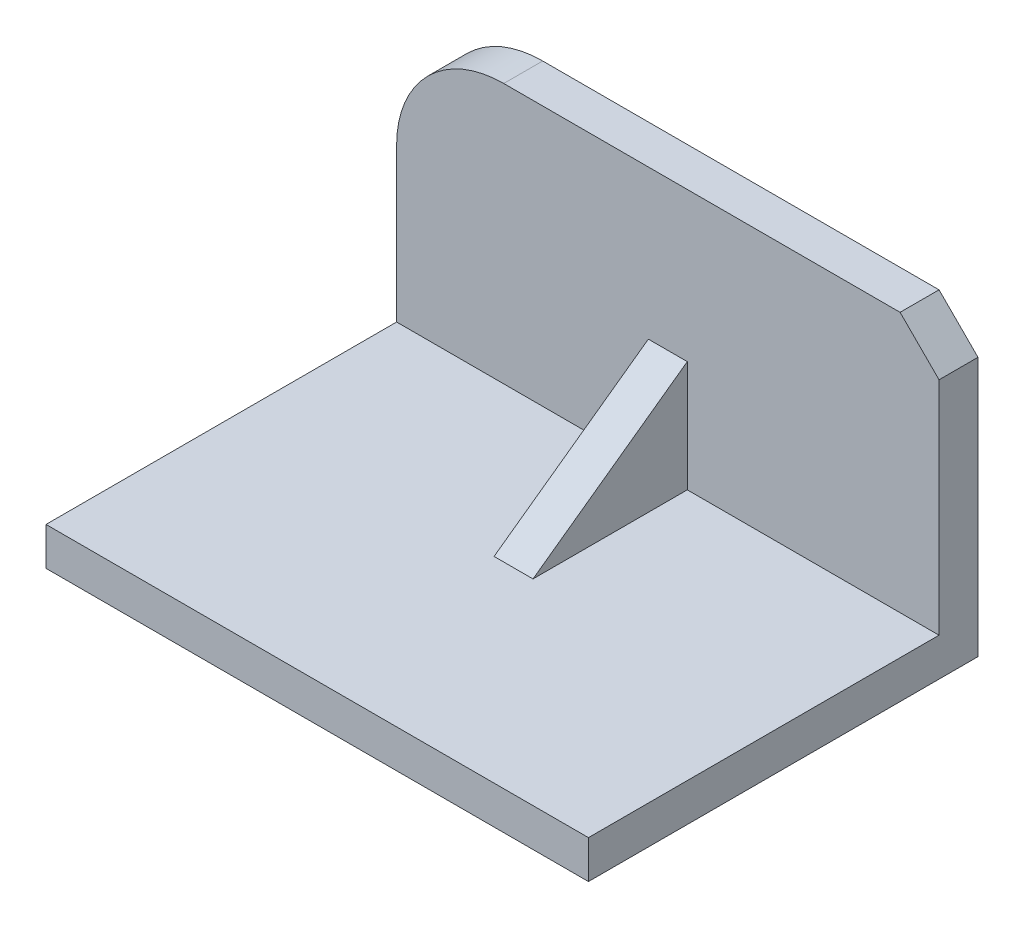
from build123d import *

# Parameters (mm, degrees)
BOSS_EXTRUDE1_DEPTH = 10
CHAMFER1_SIZE       = 10
SKETCH2_W           = 139.250997166
SKETCH2_H           = 9.771290108
BOSS_EXTRUDE2_DEPTH = 90
RIB1_REACH          = 129.722
SKETCH3_WALL_W      = 306.241984106
SKETCH3_WALL_H      = 10


with BuildPart() as part:
    # Sketch1 → Boss-Extrude1 (new body)
    with BuildSketch(Plane.XY):
        with BuildLine():
            Line((-42.118258456, 38.277525287), (69.625498583, 38.277525287))
            Line((69.625498583, 38.277525287), (69.625498583, -38.277525287))
            Line((69.625498583, -38.277525287), (-69.625498583, -38.277525287))
            Line((-69.625498583, -38.277525287), (-69.625498583, 10.77028516))
            ThreePointArc((-69.625498583, 10.77028516), (-61.568814481, 30.220841186), (-42.118258456, 38.277525287))
        make_face()
    extrude(amount=BOSS_EXTRUDE1_DEPTH)

    # Chamfer1
    chamfer1_edges = [part.edges().sort_by_distance(p)[0] for p in [
        (69.625498583, 38.277525287, 5),
    ]]
    chamfer(chamfer1_edges, length=CHAMFER1_SIZE)

    # Sketch2 → Boss-Extrude2 (add)
    with BuildSketch(Plane.XY.offset(10)):
        with Locations((0, -33.391880233)):
            Rectangle(SKETCH2_W, SKETCH2_H)
    extrude(amount=BOSS_EXTRUDE2_DEPTH)

    # Sketch3 wall → Rib1 (add, up to next)
    with BuildSketch(Plane(origin=(0, -14.25311759, 29.803162332), x_dir=(0, 0.584165456178, -0.811634597469), z_dir=(0, 0.811634597469, 0.584165456178)), mode=Mode.PRIVATE) as rib1_sk1:
        Rectangle(SKETCH3_WALL_W, SKETCH3_WALL_H)
    rib1_tool1 = extrude(rib1_sk1.sketch, amount=-RIB1_REACH, mode=Mode.PRIVATE) - part.part
    add(rib1_tool1.solids().sort_by_distance((0, -14.25311759, 29.803162332))[0])


solid = part.part
